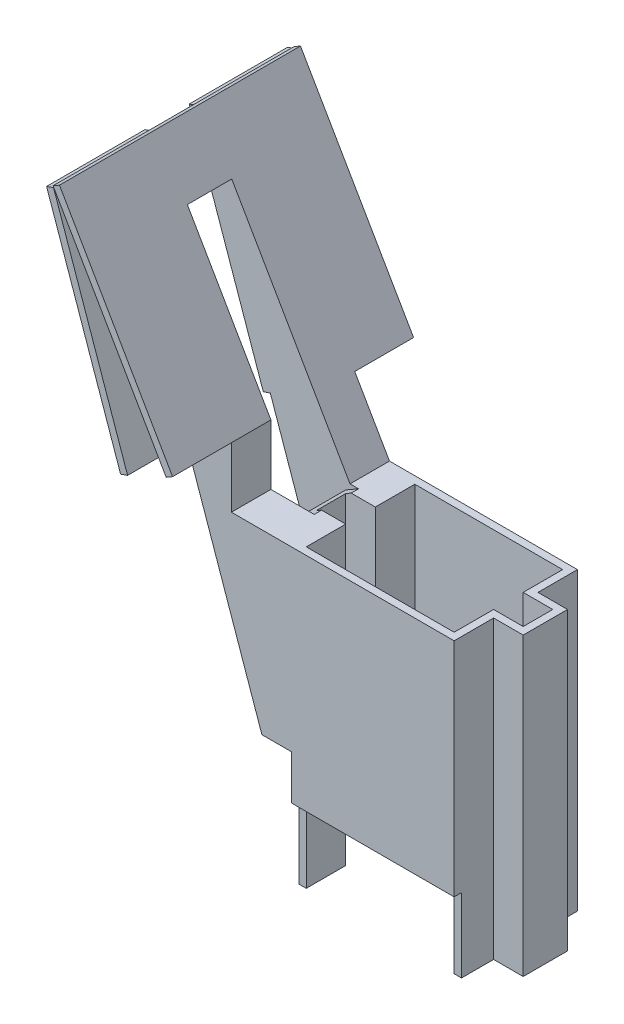
from build123d import *

# Parameters (mm, degrees)
AUFSATZ_LINEAR_AUSTRAGEN1_DEPTH  = 20
SCHNITT_LINEAR_AUSTRAGEN2_REACH  = 2.5
SKIZZE8_W                        = 11
SKIZZE8_H                        = 5
AUFSATZ_LINEAR_AUSTRAGEN3_DEPTH  = 8.34
SCHNITT_LINEAR_AUSTRAGEN3_REACH  = 19.821
SKIZZE12_W                       = 1.5
SKIZZE12_H                       = 2
AUFSATZ_LINEAR_AUSTRAGEN4_DEPTH  = 3.98
AUFSATZ_LINEAR_AUSTRAGEN5_DEPTH  = 2.67
AUFSATZ_LINEAR_AUSTRAGEN6_DEPTH  = 2.67
SCHNITT_LINEAR_AUSTRAGEN4_REACH  = 23.901
SKIZZE17_W                       = 3
SKIZZE17_H                       = 16.288675134
AUFSATZ_LINEAR_AUSTRAGEN15_DEPTH = 6.65
SCHNITT_LINEAR_AUSTRAGEN5_REACH  = 14.32


with BuildPart() as part:
    # Skizze1 → Aufsatz-Linear austragen1 (new body)
    with BuildSketch(Plane(origin=(0, 0, 0), x_dir=(1, 0, 0), z_dir=(0, 1, 0))):
        Polygon((5.5, -4.17), (-5.5, -4.17), (-5.5, -1.5), (-7.5, -1.5), (-7.5, 1.5), (-5.5, 1.5), (-5.5, 4.17), (5.5, 4.17), (5.5, 1.5), (7.5, 1.5), (7.5, -1.5), (5.5, -1.5), align=None)
        Polygon((-5, 1), (-5, 3.67), (5, 3.67), (5, 1), (7, 1), (7, -1), (5, -1), (5, -3.67), (-5, -3.67), (-5, -1), (-7, -1), (-7, 1), align=None, mode=Mode.SUBTRACT)
    extrude(amount=AUFSATZ_LINEAR_AUSTRAGEN1_DEPTH)

    # Skizze8 → Schnitt-Linear austragen2 (cut, up to next)
    with BuildSketch(Plane(origin=(0, 0, 3.67), x_dir=(-1, 0, 0), z_dir=(0, 0, -1)), mode=Mode.PRIVATE) as schnitt_linear_austragen2_sk1:
        with Locations((0, 2.5)):
            Rectangle(SKIZZE8_W, SKIZZE8_H)
    schnitt_linear_austragen2_tool1 = extrude(schnitt_linear_austragen2_sk1.sketch, amount=-SCHNITT_LINEAR_AUSTRAGEN2_REACH, mode=Mode.PRIVATE) & part.part
    add(schnitt_linear_austragen2_tool1.solids().sort_by_distance((0, 2.5, 3.67))[0], mode=Mode.SUBTRACT)

    # Skizze10 → Aufsatz-Linear austragen3 (add)
    with BuildSketch(Plane(origin=(0, 0, -4.17), x_dir=(-1, 0, 0), z_dir=(0, 0, -1))):
        Polygon((5.5, 20), (7.211324865, 20), (17.211324865, 37.320508076), (17.644337567, 37.070508076), (7.5, 19.5), (5.5, 19.5), align=None)
    extrude(amount=-AUFSATZ_LINEAR_AUSTRAGEN3_DEPTH)

    # Skizze12 → Schnitt-Linear austragen3 (cut, up to next)
    with BuildSketch(Plane.XZ.offset(-19.5), mode=Mode.PRIVATE) as schnitt_linear_austragen3_sk1:
        with Locations((-6.25, 0)):
            Rectangle(SKIZZE12_W, SKIZZE12_H)
    schnitt_linear_austragen3_tool1 = extrude(schnitt_linear_austragen3_sk1.sketch, amount=-SCHNITT_LINEAR_AUSTRAGEN3_REACH, mode=Mode.PRIVATE) & part.part
    add(schnitt_linear_austragen3_tool1.solids().sort_by_distance((-6.25, 19.5, 0))[0], mode=Mode.SUBTRACT)

    # Skizze13 → Aufsatz-Linear austragen4 (add)
    with BuildSketch(Plane(origin=(0, 0, -4.17), x_dir=(-1, 0, 0), z_dir=(0, 0, -1))):
        Polygon((17.211324865, 37.320508076), (9.561324865, 24.070319398), (9.994337567, 23.820319398), (17.644337567, 37.070508076), align=None)
    aufsatz_linear_austragen4 = extrude(amount=AUFSATZ_LINEAR_AUSTRAGEN4_DEPTH)

    # Skizze15 → Aufsatz-Linear austragen5 (add)
    with BuildSketch(Plane(origin=(0, 0, -1.5), x_dir=(-1, 0, 0), z_dir=(0, 0, -1))):
        Polygon((5.5, 8), (5.5, 19.5), (7.5, 19.5), (17.644337567, 37.070508076), (7.5, 8), align=None)
    extrude(amount=AUFSATZ_LINEAR_AUSTRAGEN5_DEPTH)

    # Spiegeln1: Aufsatz-Linear austragen4 across plane
    add(aufsatz_linear_austragen4.mirror(Plane.XY))

    # Skizze16 → Aufsatz-Linear austragen6 (add)
    with BuildSketch(Plane.XY.offset(1.5)):
        Polygon((-17.644337567, 37.070508076), (-7.5, 8), (-5.5, 8), (-5.5, 19.5), (-7.5, 19.5), align=None)
    extrude(amount=AUFSATZ_LINEAR_AUSTRAGEN6_DEPTH)

    # Skizze17 → Schnitt-Linear austragen4 (cut, up to next)
    with BuildSketch(Plane(origin=(2.818747687, 1.627404736, 0), x_dir=(0, 0, 1), z_dir=(-0.866025404, -0.5, 0)), mode=Mode.PRIVATE) as schnitt_linear_austragen4_sk1:
        with Locations((0, 28.781832941)):
            Rectangle(SKIZZE17_W, SKIZZE17_H)
    schnitt_linear_austragen4_tool1 = extrude(schnitt_linear_austragen4_sk1.sketch, amount=-SCHNITT_LINEAR_AUSTRAGEN4_REACH, mode=Mode.PRIVATE) & part.part
    add(schnitt_linear_austragen4_tool1.solids().sort_by_distance((-11.572169, 26.553203, 0))[0], mode=Mode.SUBTRACT)

    # Skizze22 → Aufsatz-Linear austragen15 (add)
    with BuildSketch(Plane.XY.offset(-1.5)):
        Polygon((-17.611390326, 36.976091556), (-12.603409607, 22.624780496), (-13.075492208, 22.460044288), (-18.083472926, 36.811355348), align=None)
    aufsatz_linear_austragen15 = extrude(amount=-AUFSATZ_LINEAR_AUSTRAGEN15_DEPTH)

    # Spiegeln2: Aufsatz-Linear austragen15 across plane
    add(aufsatz_linear_austragen15.mirror(Plane.XY))

    # Skizze23 → Schnitt-Linear austragen5 (cut, up to next)
    with BuildSketch(Plane.XY.offset(4.17), mode=Mode.PRIVATE) as schnitt_linear_austragen5_sk1:
        Polygon((-7.211324865, 20), (-9.561324865, 20), (-9.561324865, 24.070319398), align=None)
    schnitt_linear_austragen5_tool1 = extrude(schnitt_linear_austragen5_sk1.sketch, amount=-SCHNITT_LINEAR_AUSTRAGEN5_REACH, mode=Mode.PRIVATE) & part.part
    add(schnitt_linear_austragen5_tool1.solids().sort_by_distance((-8.777992, 21.356773, 4.17))[0], mode=Mode.SUBTRACT)


solid = part.part
